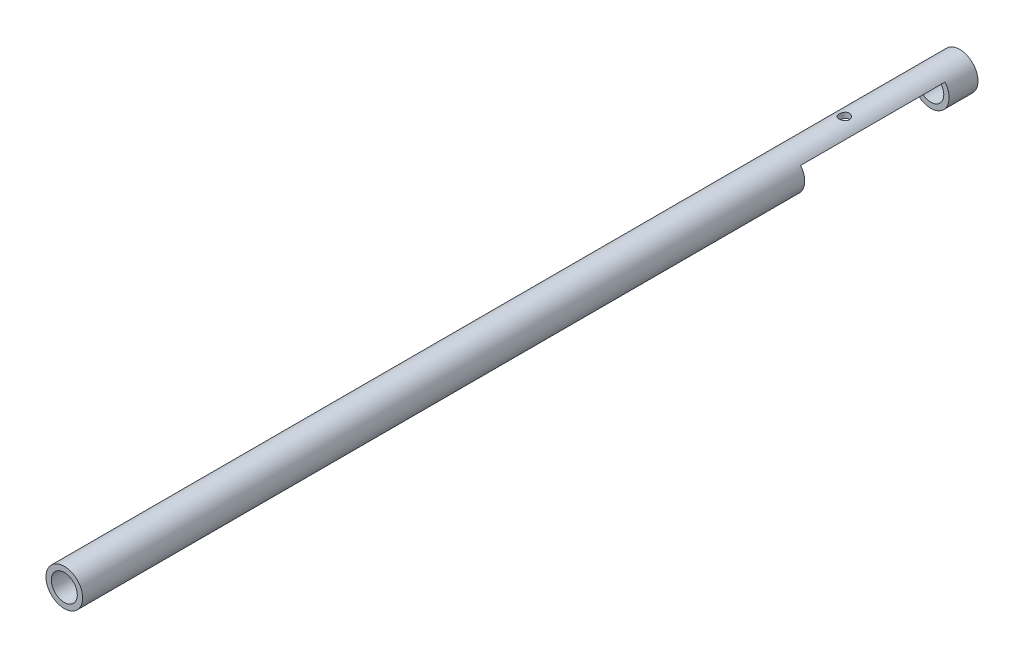
from build123d import *

# Parameters (mm, degrees)
SKETCH1_R               = 3.175
SKETCH1_R_2             = 2.25
BOSS_EXTRUDE1_DEPTH     = 35
SKETCH2_W               = 13.029993618
SKETCH2_H               = 25
CUT_EXTRUDE1_DEPTH      = 2
CUT_EXTRUDE1_DEPTH_BACK = 5
SKETCH3_R               = 0.889
F_2_56_HOLE_DEPTH       = 3
SKETCH4_R               = 3.175
SKETCH4_R_2             = 2.25
BOSS_EXTRUDE2_DEPTH     = 120


with BuildPart() as part:
    # Sketch1 → Boss-Extrude1 (new body)
    with BuildSketch(Plane.XY):
        Circle(SKETCH1_R)
        Circle(SKETCH1_R_2, mode=Mode.SUBTRACT)
    extrude(amount=BOSS_EXTRUDE1_DEPTH)

    # Sketch2 → Cut-Extrude1 (cut, two sides)
    with BuildSketch(Plane(origin=(0, 0, 0), x_dir=(1, 0, 0), z_dir=(0, 1, 0))) as cut_extrude1_sk:
        with Locations((0.986854582, -17.5)):
            Rectangle(SKETCH2_W, SKETCH2_H)
    extrude(amount=CUT_EXTRUDE1_DEPTH, mode=Mode.SUBTRACT)
    extrude(cut_extrude1_sk.sketch, amount=-CUT_EXTRUDE1_DEPTH_BACK, mode=Mode.SUBTRACT)

    # Sketch3 → 2-56 hole (cut)
    with BuildSketch(Plane(origin=(0, 2, 0), x_dir=(-1, 0, 0), z_dir=(0, -1, 0))):
        with Locations((0, -20)):
            Circle(SKETCH3_R)
    extrude(amount=-F_2_56_HOLE_DEPTH, mode=Mode.SUBTRACT)

    # Sketch4 → Boss-Extrude2 (add)
    with BuildSketch(Plane.XY.offset(35)):
        Circle(SKETCH4_R)
        Circle(SKETCH4_R_2, mode=Mode.SUBTRACT)
    extrude(amount=BOSS_EXTRUDE2_DEPTH)


solid = part.part
